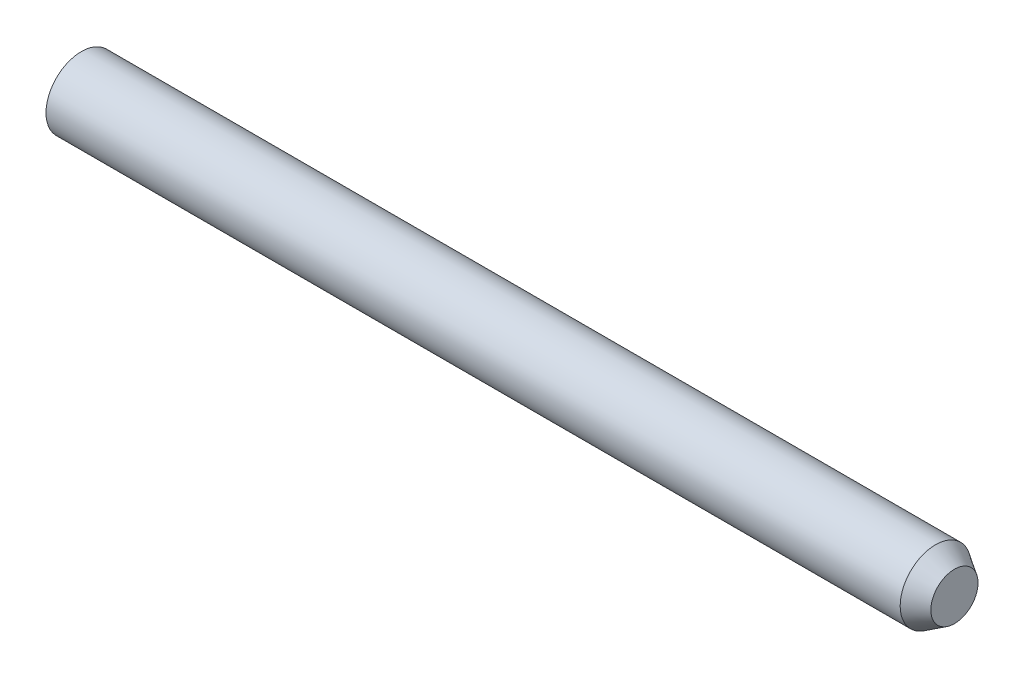
from build123d import *

# Parameters (mm, degrees)
SKETCH2_W = 11.446123423
SKETCH2_H = 10


with BuildPart() as part:
    # Sketch2 → Revolve2 (revolve)
    with BuildSketch(Plane.XY):
        Polygon((65, -10), (-65, -10), (-65, -15), (65, -15), (255, -15), (297, -15), (305, -10), (293.553876577, -10), align=None)
        with Locations((299.276938288, -5)):
            Rectangle(SKETCH2_W, SKETCH2_H)
    revolve(axis=Axis((-65, 0, 0), (1, 0, 0)))


solid = part.part
